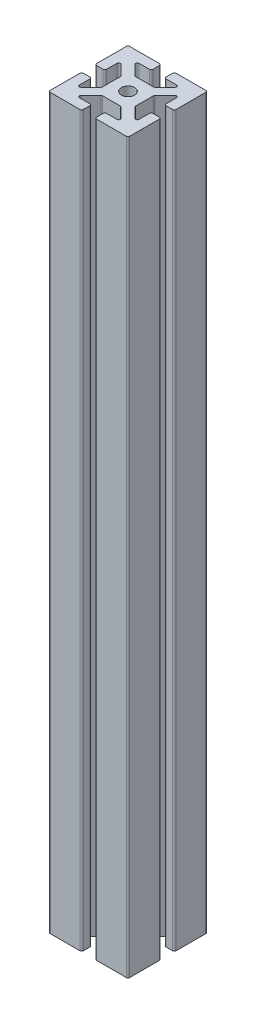
from build123d import *

# Parameters (mm, degrees)
SKETCH1_R           = 1
BOSS_EXTRUDE2_DEPTH = 55
FILLET2_R           = 0.25


with BuildPart() as part:
    # Sketch1 → Boss-Extrude2 (new body, symmetric)
    with BuildSketch(Plane(origin=(0, 0, 0), x_dir=(1, 0, 0), z_dir=(0, 1, 0))):
        Polygon((1, 6), (6, 6), (6, 1), (4.5, 1), (4.5, 3.439339828), (2.5, 1.439339828), (2.5, -1.439339828), (4.5, -3.439339828), (4.5, -1), (6, -1), (6, -6), (1, -6), (1, -4.5), (3.439339828, -4.5), (1.439339828, -2.5), (-1.439339828, -2.5), (-3.439339828, -4.5), (-1, -4.5), (-1, -6), (-6, -6), (-6, -1), (-4.5, -1), (-4.5, -3.439339828), (-2.5, -1.439339828), (-2.5, 1.439339828), (-4.5, 3.439339828), (-4.5, 1), (-6, 1), (-6, 6), (-1, 6), (-1, 4.5), (-3.439339828, 4.5), (-1.439339828, 2.5), (1.439339828, 2.5), (3.439339828, 4.5), (1, 4.5), align=None)
        Circle(SKETCH1_R, mode=Mode.SUBTRACT)
    extrude(amount=BOSS_EXTRUDE2_DEPTH, both=True)

    # Fillet2
    fillet2_edges = [part.edges().sort_by_distance(p)[0] for p in [
        (6, 0, -6),
        (6, 0, -1),
        (4.5, 0, -1),
        (4.5, 0, -3.439339828),
        (2.5, 0, -1.439339828),
        (2.5, 0, 1.439339828),
        (4.5, 0, 3.439339828),
        (4.5, 0, 1),
        (6, 0, 1),
        (6, 0, 6),
        (1, 0, 6),
        (1, 0, 4.5),
        (3.439339828, 0, 4.5),
        (1.439339828, 0, 2.5),
        (-1.439339828, 0, 2.5),
        (-3.439339828, 0, 4.5),
        (-1, 0, 4.5),
        (-1, 0, 6),
        (-6, 0, 6),
        (-6, 0, 1),
        (-4.5, 0, 1),
        (-4.5, 0, 3.439339828),
        (-2.5, 0, 1.439339828),
        (-2.5, 0, -1.439339828),
        (-4.5, 0, -3.439339828),
        (-4.5, 0, -1),
        (-6, 0, -1),
        (-6, 0, -6),
        (-1, 0, -6),
        (-1, 0, -4.5),
        (-3.439339828, 0, -4.5),
        (-1.439339828, 0, -2.5),
        (1.439339828, 0, -2.5),
        (3.439339828, 0, -4.5),
        (1, 0, -4.5),
        (1, 0, -6),
    ]]
    fillet(fillet2_edges, radius=FILLET2_R)


solid = part.part
